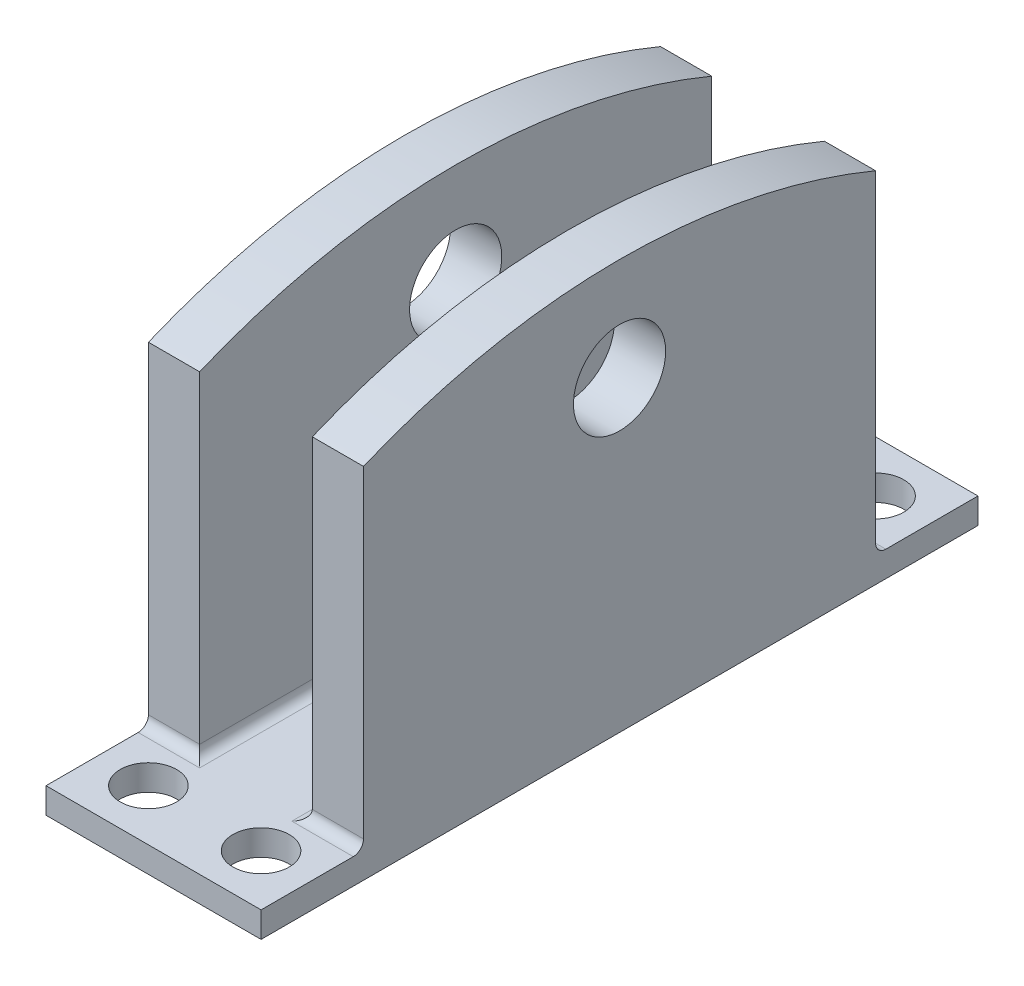
from build123d import *

# Parameters (mm, degrees)
BOSS_EXTRUDE1_DEPTH      = 50
CUT_EXTRUDE1_DEPTH       = 22
M8_CLEARANCE_HOLE1_D     = 9
M8_CLEARANCE_HOLE1_DEPTH = 30
M8_CLEARANCE_HOLE1_TIP   = 2.703872786
SKETCH6_W                = 21
SKETCH6_H                = 10
BOSS_EXTRUDE2_DEPTH      = 2.5
FILLET1_R                = 1
M5_CLEARANCE_HOLE1_D     = 5.5


with BuildPart() as part:
    # Sketch1 → Boss-Extrude1 (new body)
    with BuildSketch(Plane.XY):
        Polygon((0.253520576, 50), (5.253520576, 50), (5.253520576, 2.5), (16.253520576, 2.5), (16.253520576, 50), (21.253520576, 50), (21.253520576, 0), (0.253520576, 0), align=None)
    extrude(amount=BOSS_EXTRUDE1_DEPTH)

    # Sketch2 → Cut-Extrude1 (cut, through all)
    with BuildSketch(Plane(origin=(21.253520576, 0, 0), x_dir=(0, 0, -1), z_dir=(1, 0, 0))):
        with BuildLine():
            Line((-50, 35), (-50, 50))
            Line((-50, 50), (0, 50))
            Line((0, 50), (0, 35))
            ThreePointArc((0, 35), (-25, 40), (-50, 35))
        make_face()
    extrude(amount=-CUT_EXTRUDE1_DEPTH, mode=Mode.SUBTRACT)

    # M8 Clearance Hole1
    with Locations(Plane(origin=(21.253520576, 0, 0), x_dir=(0, 0, -1), z_dir=(1, 0, 0))):
        with Locations((-25, 30)):
            Hole(M8_CLEARANCE_HOLE1_D / 2, depth=M8_CLEARANCE_HOLE1_DEPTH)
            with Locations((0, 0, -(M8_CLEARANCE_HOLE1_DEPTH + M8_CLEARANCE_HOLE1_TIP / 2))):  # 118° drill point
                Cone(0, M8_CLEARANCE_HOLE1_D / 2, M8_CLEARANCE_HOLE1_TIP, mode=Mode.SUBTRACT)

    # Sketch6 → Boss-Extrude2 (add)
    with BuildSketch(Plane.XZ):
        with Locations((10.753520576, -5)):
            Rectangle(SKETCH6_W, SKETCH6_H)
        with Locations((10.753520576, 55)):
            Rectangle(SKETCH6_W, SKETCH6_H)
    extrude(amount=-BOSS_EXTRUDE2_DEPTH)

    # Fillet1
    fillet1_edges = [part.edges().sort_by_distance(p)[0] for p in [
        (5.253520576, 2.5, 25),
        (16.253520576, 2.5, 25),
        (2.753520576, 2.5, 0),
        (18.753520576, 2.5, 0),
        (18.753520576, 2.5, 50),
        (2.753520576, 2.5, 50),
    ]]
    fillet(fillet1_edges, radius=FILLET1_R)

    # M5 Clearance Hole1 (through all)
    with Locations(Plane(origin=(0, 2.5, 0), x_dir=(1, 0, 0), z_dir=(0, 1, 0))):
        with Locations((5.253520576, -55), (16.253520576, -55), (5.253520576, 5), (16.253520576, 5)):
            Hole(M5_CLEARANCE_HOLE1_D / 2)


solid = part.part
